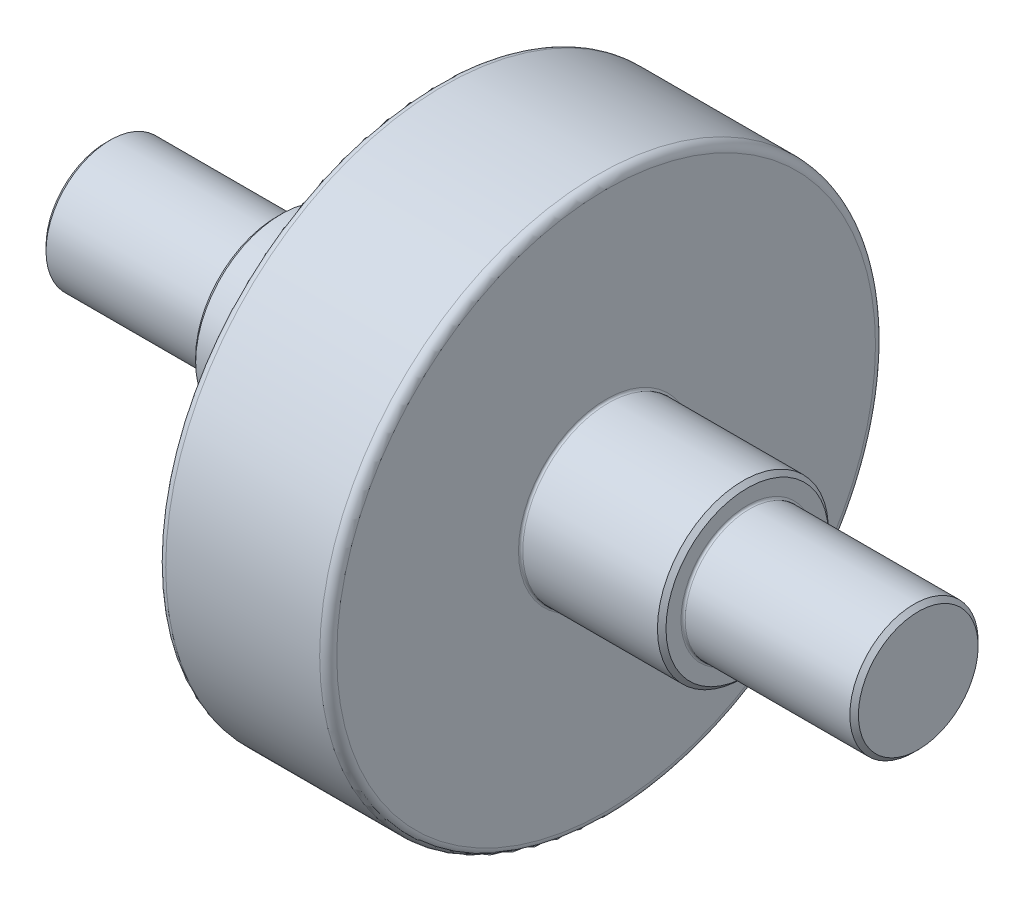
from build123d import *


with BuildPart() as part:
    # 草图1 → 旋转1 (revolve)
    with BuildSketch(Plane.XY):
        with BuildLine():
            Line((0, 0), (190, 0))
            Line((190, 0), (190, 14))
            Line((190, 14), (189, 15))
            Line((189, 15), (150.5, 15))
            ThreePointArc((150.5, 15), (150.146446609, 15.146446609), (150, 15.5))
            Line((150, 15.5), (150, 19))
            Line((150, 19), (149, 20))
            Line((149, 20), (117.5, 20))
            ThreePointArc((117.5, 20), (117.146446609, 20.146446609), (117, 20.5))
            Line((117, 20.5), (117, 63))
            ThreePointArc((117, 63), (116.414213562, 64.414213562), (115, 65))
            Line((115, 65), (79, 65))
            ThreePointArc((79, 65), (77.585786438, 64.414213562), (77, 63))
            Line((77, 63), (77, 20.5))
            ThreePointArc((77, 20.5), (76.853553391, 20.146446609), (76.5, 20))
            Line((76.5, 20), (41, 20))
            Line((41, 20), (40, 19))
            Line((40, 19), (40, 15.5))
            ThreePointArc((40, 15.5), (39.853553391, 15.146446609), (39.5, 15))
            Line((39.5, 15), (1, 15))
            Line((1, 15), (0, 14))
            Line((0, 14), (0, 0))
        make_face()
    revolve(axis=Axis((0, 0, 0), (1, 0, 0)))


solid = part.part
